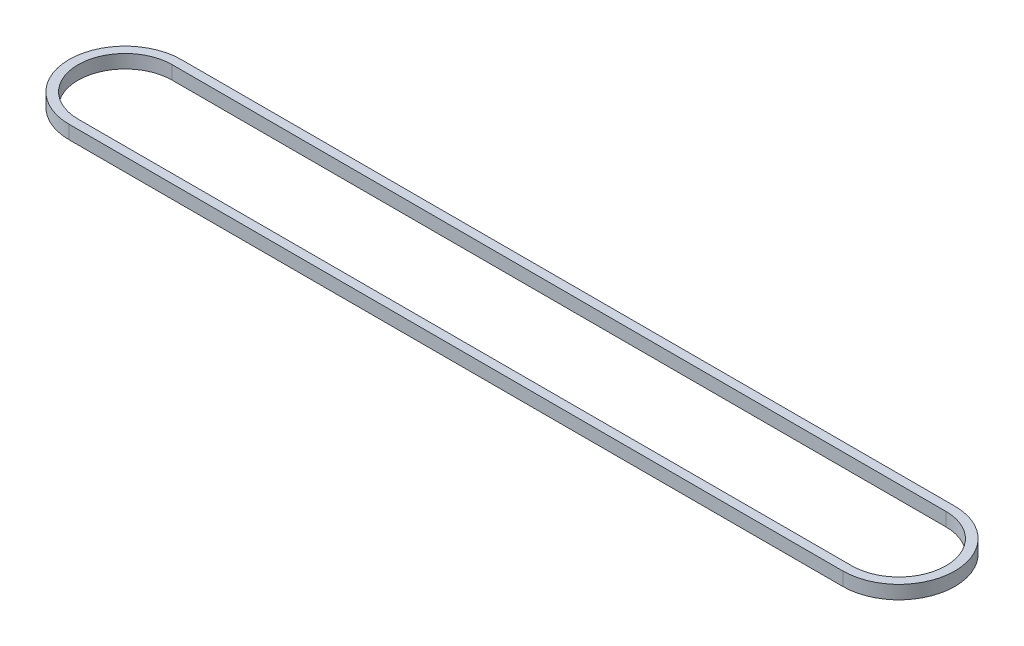
from build123d import *

# Parameters (mm, degrees)
BOSS_EXTRUDE1_DEPTH = 3


with BuildPart() as part:
    # Sketch1 → Boss-Extrude1 (new body)
    with BuildSketch(Plane(origin=(0, 0, 0), x_dir=(1, 0, 0), z_dir=(0, 1, 0))):
        with BuildLine():
            Line((-32.668928407, 12.5), (139.831071593, 12.5))
            ThreePointArc((139.831071593, 12.5), (152.331071593, 0), (139.831071593, -12.5))
            Line((139.831071593, -12.5), (-32.668928407, -12.5))
            ThreePointArc((-32.668928407, -12.5), (-45.168928407, 0), (-32.668928407, 12.5))
        make_face()
        with BuildLine():
            Line((-32.668928407, 10.5), (139.831071593, 10.5))
            ThreePointArc((139.831071593, 10.5), (150.331071593, 0), (139.831071593, -10.5))
            Line((139.831071593, -10.5), (-32.668928407, -10.5))
            ThreePointArc((-32.668928407, -10.5), (-43.168928407, 0), (-32.668928407, 10.5))
        make_face(mode=Mode.SUBTRACT)
    extrude(amount=BOSS_EXTRUDE1_DEPTH)


solid = part.part
